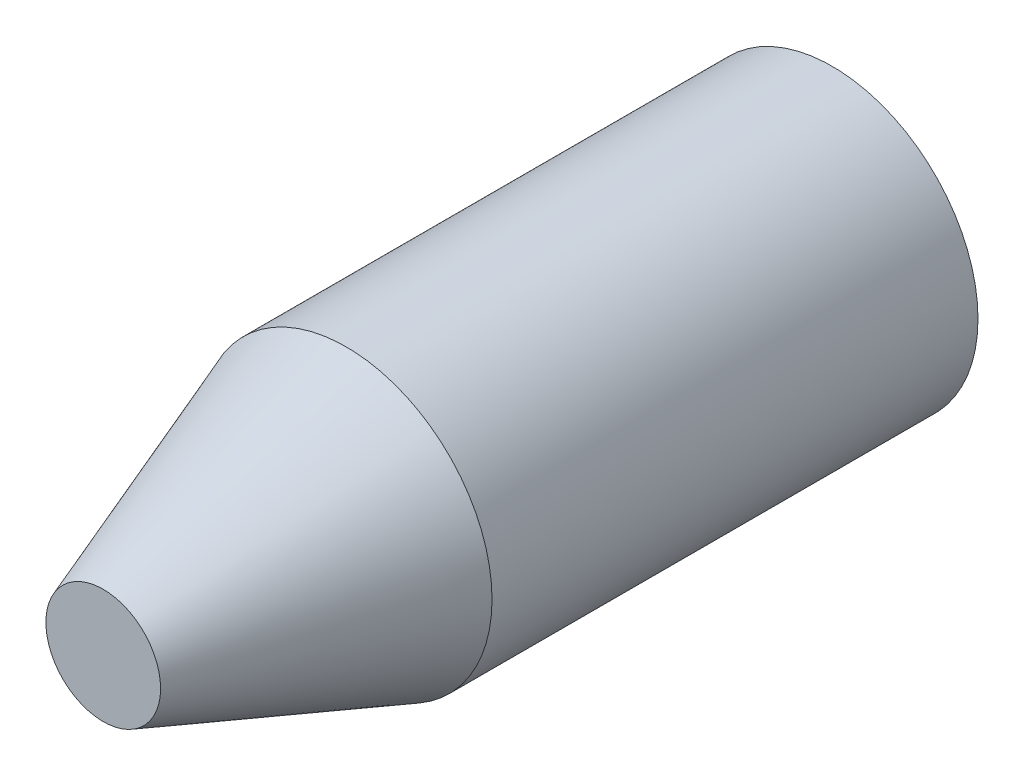
from build123d import *

# Parameters (mm, degrees)
SKETCH1_R           = 3
BOSS_EXTRUDE1_DEPTH = 10
SKETCH2_R           = 3
BOSS_EXTRUDE2_DEPTH = 5
BOSS_EXTRUDE2_TAPER = 20


with BuildPart() as part:
    # Sketch1 → Boss-Extrude1 (new body)
    with BuildSketch(Plane.XY):
        Circle(SKETCH1_R)
    extrude(amount=BOSS_EXTRUDE1_DEPTH)

    # Sketch2 → Boss-Extrude2 (add)
    with BuildSketch(Plane.XY.offset(10)):
        Circle(SKETCH2_R)
    extrude(amount=BOSS_EXTRUDE2_DEPTH, taper=BOSS_EXTRUDE2_TAPER)


solid = part.part
